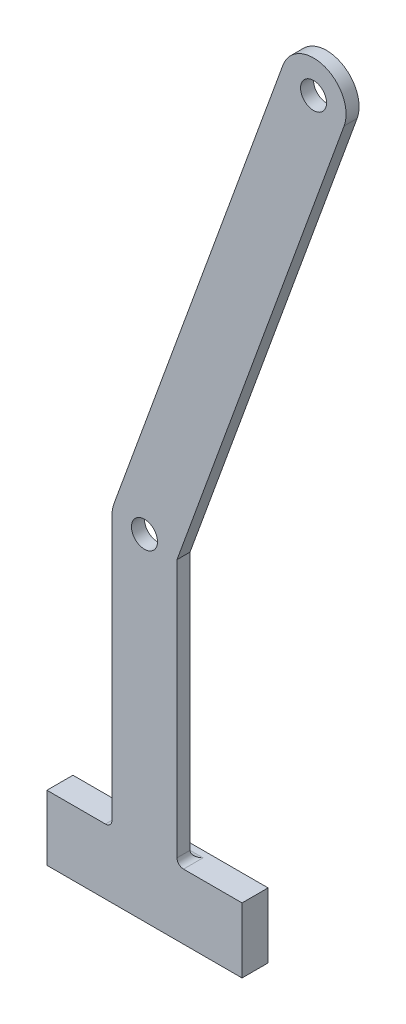
from build123d import *

# Parameters (mm, degrees)
SKETCH1_R           = 2.54
BOSS_EXTRUDE1_DEPTH = 2.54
SKETCH2_W           = 38.1
SKETCH2_H           = 12.7
BOSS_EXTRUDE2_DEPTH = 2.54
FILLET1_R           = 1.27


with BuildPart() as part:
    # Sketch1 → Boss-Extrude1 (new body)
    with BuildSketch(Plane.XY):
        with BuildLine():
            Line((-54.601784234, -110.868808086), (-21.972951858, -21.22182791))
            ThreePointArc((-21.972951858, -21.22182791), (-25.76817209, -13.082951858), (-33.907048142, -16.87817209))
            Line((-33.907048142, -16.87817209), (-66.918832376, -107.577303848))
            ThreePointArc((-66.918832376, -107.577303848), (-67.205313465, -108.64646583), (-67.301784234, -109.749131758))
            Line((-67.301784234, -109.749131758), (-67.301784234, -162.56))
            Line((-67.301784234, -162.56), (-80.001784234, -162.56))
            Line((-80.001784234, -162.56), (-80.001784234, -175.26))
            Line((-80.001784234, -175.26), (-41.901784234, -175.26))
            Line((-41.901784234, -175.26), (-41.901784234, -162.56))
            Line((-41.901784234, -162.56), (-54.601784234, -162.56))
            Line((-54.601784234, -162.56), (-54.601784234, -110.868808086))
        make_face()
        with Locations((-27.94, -19.05)):
            Circle(SKETCH1_R, mode=Mode.SUBTRACT)
        with Locations((-60.951784234, -109.749131758)):
            Circle(SKETCH1_R, mode=Mode.SUBTRACT)
    extrude(amount=BOSS_EXTRUDE1_DEPTH)

    # Sketch2 → Boss-Extrude2 (add)
    with BuildSketch(Plane(origin=(0, 0, 0), x_dir=(-1, 0, 0), z_dir=(0, 0, -1))):
        with Locations((60.951784234, -168.91)):
            Rectangle(SKETCH2_W, SKETCH2_H)
    extrude(amount=BOSS_EXTRUDE2_DEPTH)

    # Fillet1
    fillet1_edges = [part.edges().sort_by_distance(p)[0] for p in [
        (-54.601784234, -162.56, 1.27),
        (-67.301784234, -162.56, 1.27),
        (-60.951784234, -162.56, 0),
    ]]
    fillet(fillet1_edges, radius=FILLET1_R)


solid = part.part
